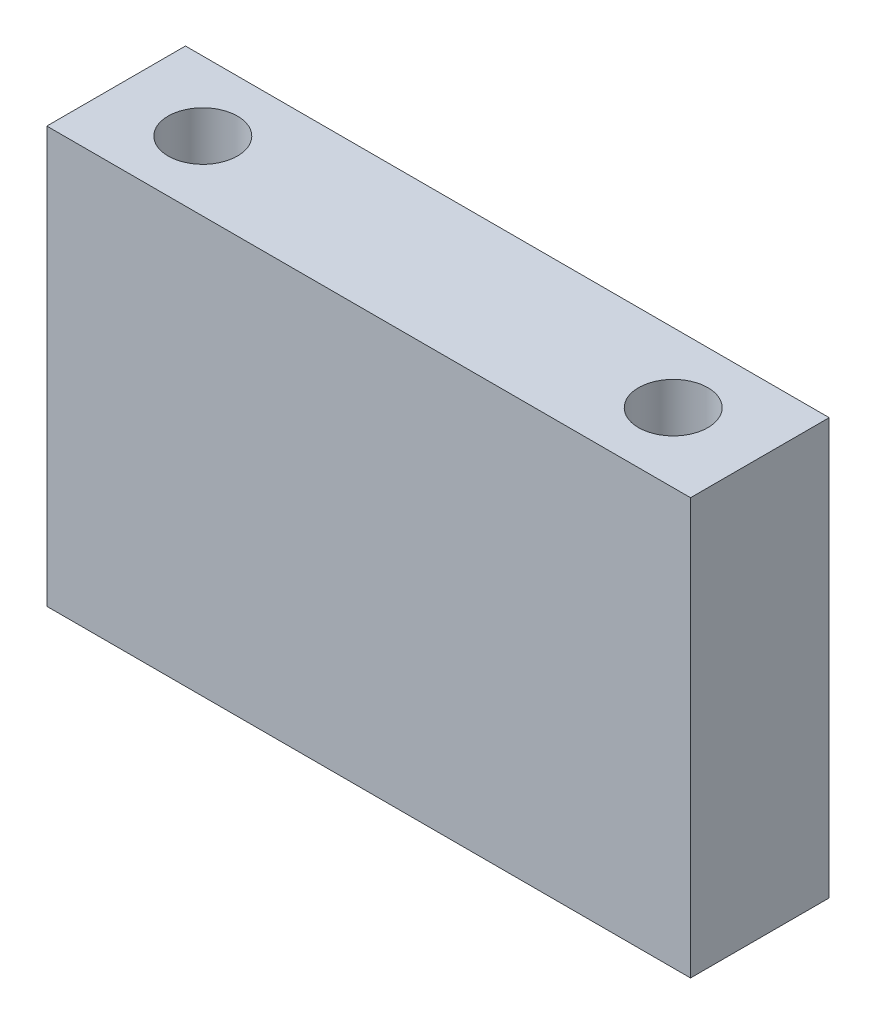
from build123d import *

# Parameters (mm, degrees)
SKETCH1_W      = 65
SKETCH1_H      = 42
EXTRUDE1_DEPTH = 14
SKETCH2_R      = 3.5
EXTRUDE2_DEPTH = 43


with BuildPart() as part:
    # Sketch1 → Extrude1 (new body)
    with BuildSketch(Plane.XY):
        with Locations((32.5, 21)):
            Rectangle(SKETCH1_W, SKETCH1_H)
    extrude(amount=EXTRUDE1_DEPTH)

    # Sketch2 → Extrude2 (cut, through all)
    with BuildSketch(Plane(origin=(0, 42, 0), x_dir=(1, 0, 0), z_dir=(0, 1, 0))):
        with Locations(Location((8.75, -7, 0), (0, 0, 270))):  # turned: the seam where the file's is
            Circle(SKETCH2_R)
        with Locations(Location((56.25, -7, 0), (0, 0, 270))):  # turned: the seam where the file's is
            Circle(SKETCH2_R)
    extrude(amount=-EXTRUDE2_DEPTH, mode=Mode.SUBTRACT)


solid = part.part
